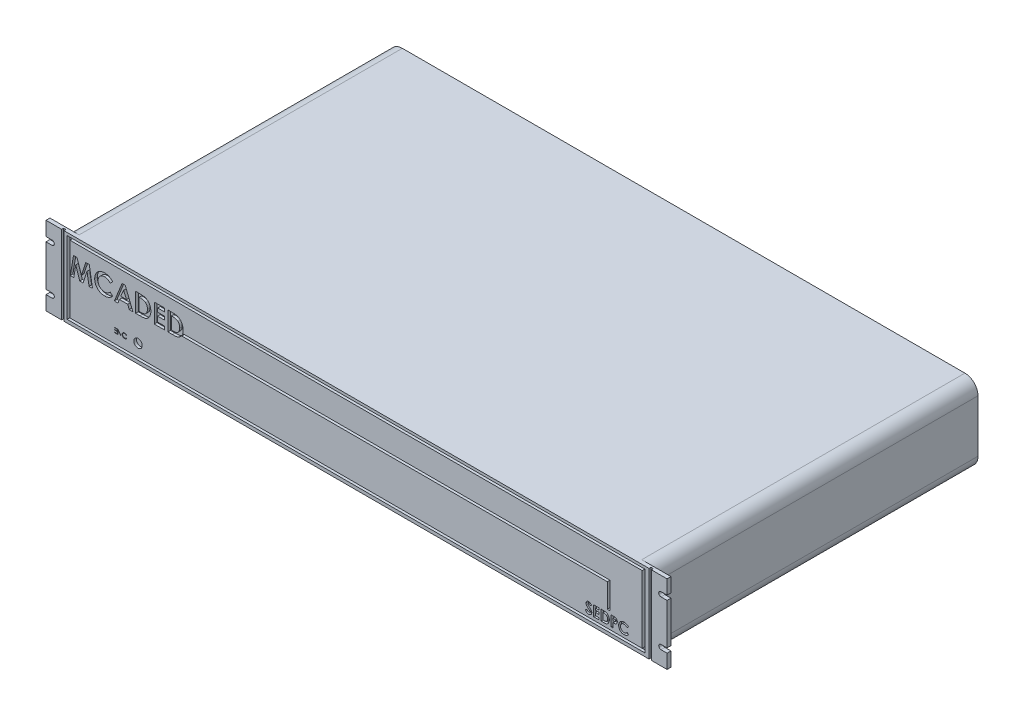
from build123d import *

# Parameters (mm, degrees)
CROQUIS1_W              = 450
CROQUIS1_H              = 60
SALIENTE_EXTRUIR1_DEPTH = 250
SALIENTE_EXTRUIR2_DEPTH = 3
CROQUIS3_W              = 1.774092819
CROQUIS3_H              = 60
CORTAR_EXTRUIR1_DEPTH   = 1.5
CROQUIS4_W              = 441.514510662
CROQUIS4_H              = 55.460871824
CROQUIS4_W_2            = 437.514510662
CROQUIS4_H_2            = 51.460871824
CORTAR_EXTRUIR2_DEPTH   = 2
CORTAR_EXTRUIR3_DEPTH   = 2
CORTAR_EXTRUIR4_DEPTH   = 2
CORTAR_EXTRUIR5_DEPTH   = 2
CORTAR_EXTRUIR6_DEPTH   = 2
CROQUIS9_R              = 3.233196097
CORTAR_EXTRUIR7_DEPTH   = 2
REDONDEO1_R             = 10
ESCALA1_SCALE           = 1.4


with BuildPart() as part:
    # Croquis1 → Saliente-Extruir1 (new body)
    with BuildSketch(Plane.XY):
        Rectangle(CROQUIS1_W, CROQUIS1_H)
    extrude(amount=-SALIENTE_EXTRUIR1_DEPTH)

    # Croquis2 → Saliente-Extruir2 (add)
    with BuildSketch(Plane.XY):
        with BuildLine():
            Line((-237.33757683, 19.209077648), (-232.703125908, 19.209077648))
            ThreePointArc((-232.703125908, 19.209077648), (-230.965960943, 17.471912682), (-232.703125908, 15.734747717))
            Line((-232.703125908, 15.734747717), (-237.33757683, 15.734747717))
            Line((-237.33757683, 15.734747717), (-237.33757683, -15.734747717))
            Line((-237.33757683, -15.734747717), (-232.703125908, -15.734747717))
            ThreePointArc((-232.703125908, -15.734747717), (-230.965960943, -17.471912682), (-232.703125908, -19.209077648))
            Line((-232.703125908, -19.209077648), (-237.33757683, -19.209077648))
            Line((-237.33757683, -19.209077648), (-237.33757683, -30))
            Line((-237.33757683, -30), (-225, -30))
            Line((-225, -30), (-225, 30))
            Line((-225, 30), (-237.33757683, 30))
            Line((-237.33757683, 30), (-237.33757683, 19.209077648))
        make_face()
        with BuildLine():
            Line((237.33757683, -19.209077648), (237.33757683, -30))
            Line((237.33757683, -30), (225, -30))
            Line((225, -30), (225, 30))
            Line((225, 30), (237.33757683, 30))
            Line((237.33757683, 30), (237.33757683, 19.209077648))
            Line((237.33757683, 19.209077648), (232.703125908, 19.209077648))
            ThreePointArc((232.703125908, 19.209077648), (230.965960943, 17.471912682), (232.703125908, 15.734747717))
            Line((232.703125908, 15.734747717), (237.33757683, 15.734747717))
            Line((237.33757683, 15.734747717), (237.33757683, -15.734747717))
            Line((237.33757683, -15.734747717), (232.703125908, -15.734747717))
            ThreePointArc((232.703125908, -15.734747717), (230.965960943, -17.471912682), (232.703125908, -19.209077648))
            Line((232.703125908, -19.209077648), (237.33757683, -19.209077648))
        make_face()
    extrude(amount=-SALIENTE_EXTRUIR2_DEPTH)

    # Croquis3 → Cortar-Extruir1 (cut)
    with BuildSketch(Plane.XY):
        with Locations((-224.462831351, 0)):
            Rectangle(CROQUIS3_W, CROQUIS3_H)
        with Locations((224.462831351, 0)):
            Rectangle(CROQUIS3_W, CROQUIS3_H)
    extrude(amount=-CORTAR_EXTRUIR1_DEPTH, mode=Mode.SUBTRACT)

    # Croquis4 → Cortar-Extruir2 (cut)
    with BuildSketch(Plane.XY):
        with Locations((-0.390933447, 0.235625417)):
            Rectangle(CROQUIS4_W, CROQUIS4_H)
        with Locations((-0.390933447, 0.235625417)):
            Rectangle(CROQUIS4_W_2, CROQUIS4_H_2, mode=Mode.SUBTRACT)
    extrude(amount=-CORTAR_EXTRUIR2_DEPTH, mode=Mode.SUBTRACT)

    # Croquis5 → Cortar-Extruir3 (cut)
    with BuildSketch(Plane.XY):
        Polygon((-133.60240972, 7.292609146), (193.704759811, 7.292609146), (193.704759811, -12.940905954), (191.704759811, -12.940905954), (191.704759811, 5.292609146), (-133.60240972, 5.292609146), align=None)
    extrude(amount=-CORTAR_EXTRUIR3_DEPTH, mode=Mode.SUBTRACT)

    # Croquis6 → Cortar-Extruir4 (cut)
    with BuildSketch(Plane.XY):
        Polygon((-216.317645325, 17.239226917), (-213.606620185, 17.239226917), (-210.286343158, 7.088915585), (-206.942745485, 17.239226917), (-204.257956072, 17.239226917), (-201.79762788, 2.687143583), (-204.441606162, 2.687143583), (-205.995344226, 11.878393333), (-209.021198093, 2.687143583), (-211.568978708, 2.687143583), (-214.57734209, 11.878393333), (-216.128165073, 2.687143583), (-218.775058436, 2.687143583), align=None)
        with BuildLine():
            Line((-186.312718692, 14.714766948), (-188.227926775, 12.884096208))
            add(Edge.make_bspline(
                [(-188.227926775, 12.884096208), (-188.390390328, 13.052083793), (-188.707732544, 13.380216176), (-189.219090278, 13.814634535), (-189.750883703, 14.176663457), (-190.292767839, 14.481561911), (-190.854489611, 14.712239321), (-191.429553985, 14.880337835), (-192.021632917, 14.982821146), (-192.422329165, 14.994547051), (-192.623868615, 15.000444866)],
                knots=[0, 0, 0, 0, 0.000700833, 0.001368946, 0.002008519, 0.002628308, 0.003230835, 0.003825862, 0.004422991, 0.005027264, 0.005027264, 0.005027264, 0.005027264], degree=3))
            add(Edge.make_bspline(
                [(-192.623868615, 15.000444866), (-192.792178549, 14.995785386), (-193.124319658, 14.986590415), (-193.611989843, 14.919182212), (-194.078471579, 14.80455163), (-194.525361706, 14.646569454), (-194.951345231, 14.442148903), (-195.357315281, 14.191448193), (-195.742270954, 13.896731509), (-196.101127208, 13.559523727), (-196.429396297, 13.191098886), (-196.71944294, 12.797990459), (-196.96240353, 12.381099037), (-197.161797334, 11.944646588), (-197.317117399, 11.486612995), (-197.42803544, 11.007306624), (-197.49218747, 10.506156658), (-197.501762591, 10.165478646), (-197.506628949, 9.992336058)],
                knots=[0, 0, 0, 0, 0.000504848, 0.000996262, 0.001473499, 0.001943722, 0.002415713, 0.002888181, 0.00337269, 0.003867671, 0.004363217, 0.00485123, 0.005330696, 0.005808138, 0.006288419, 0.006779158, 0.007281746, 0.007801154, 0.007801154, 0.007801154, 0.007801154], degree=3))
            add(Edge.make_bspline(
                [(-197.506628949, 9.992336058), (-197.50522652, 9.870812476), (-197.502462304, 9.631286998), (-197.47220307, 9.276962338), (-197.42347857, 8.933183651), (-197.352962145, 8.600471671), (-197.264780663, 8.278538067), (-197.161323706, 7.964605533), (-197.031538475, 7.66301191), (-196.88747491, 7.370254385), (-196.719930645, 7.094321213), (-196.539287019, 6.831196032), (-196.343408499, 6.582168657), (-196.13102637, 6.348257119), (-195.899151616, 6.133116932), (-195.653777343, 5.930278573), (-195.390764426, 5.744819775), (-195.115576309, 5.572086245), (-194.825835715, 5.422031157), (-194.529403978, 5.286110237), (-194.221786596, 5.175722242), (-193.906728994, 5.086739447), (-193.585357079, 5.01107287), (-193.254527533, 4.964482632), (-192.917108236, 4.929200391), (-192.689069426, 4.927021919), (-192.574312242, 4.925925635)],
                knots=[0, 0, 0, 0, 0.00036449, 0.000718417, 0.001065948, 0.001405552, 0.001737922, 0.002067017, 0.002396202, 0.002722118, 0.003045074, 0.003363659, 0.003679162, 0.003994866, 0.00431041, 0.004627296, 0.004949225, 0.005275219, 0.0056012, 0.005927377, 0.006252888, 0.00658043, 0.006909266, 0.007242377, 0.007582043, 0.007926134, 0.007926134, 0.007926134, 0.007926134], degree=3))
            add(Edge.make_bspline(
                [(-192.574312242, 4.925925635), (-192.379664336, 4.931555885), (-191.997231818, 4.942617863), (-191.435957109, 5.029120964), (-190.901118227, 5.171413669), (-190.47378452, 5.339453086), (-190.138979848, 5.505394192), (-189.884098001, 5.658881544), (-189.620530306, 5.830573998), (-189.352654396, 6.026951415), (-189.0774572, 6.245657186), (-188.799796581, 6.491481376), (-188.51256438, 6.756329347), (-188.324401413, 6.945356547), (-188.227926775, 7.042274293)],
                knots=[0, 0, 0, 0, 0.000583744, 0.001146906, 0.001699158, 0.002241026, 0.002521314, 0.00281928, 0.003132987, 0.003464756, 0.003815306, 0.004187158, 0.004577006, 0.004987205, 0.004987205, 0.004987205, 0.004987205], degree=3))
            Line((-188.227926775, 7.042274293), (-186.371020308, 5.09208524))
            add(Edge.make_bspline(
                [(-186.371020308, 5.09208524), (-186.501550838, 4.966062112), (-186.756318517, 4.720091916), (-187.140628488, 4.37083719), (-187.52445479, 4.056992994), (-187.898524979, 3.767168159), (-188.268966715, 3.509805985), (-188.635740712, 3.284649443), (-188.99469493, 3.086003998), (-189.353283167, 2.917219708), (-189.713736744, 2.773904315), (-190.084601116, 2.650519169), (-190.467010049, 2.546139774), (-190.863299124, 2.461919311), (-191.269771998, 2.394385869), (-191.690232715, 2.348801187), (-192.122015348, 2.318156121), (-192.414900198, 2.315402408), (-192.562651919, 2.314013242)],
                knots=[0, 0, 0, 0, 0.000544317, 0.00106239, 0.00155731, 0.002031331, 0.002481737, 0.002909708, 0.003321963, 0.003711865, 0.004097825, 0.004484993, 0.004883837, 0.005286351, 0.005699933, 0.006119391, 0.006554715, 0.006997893, 0.006997893, 0.006997893, 0.006997893], degree=3))
            add(Edge.make_bspline(
                [(-192.562651919, 2.314013242), (-192.834053528, 2.32093181), (-193.365111037, 2.334469525), (-194.143361969, 2.434774827), (-194.882679464, 2.602934899), (-195.584862143, 2.840759623), (-196.249686727, 3.144569562), (-196.876983135, 3.517026282), (-197.465740304, 3.957140223), (-198.011202235, 4.459752823), (-198.504598511, 5.014846247), (-198.940703681, 5.610864298), (-199.301449894, 6.250736189), (-199.600985248, 6.925008968), (-199.835217955, 7.636759602), (-200.000078072, 8.38675799), (-200.101746103, 9.174279961), (-200.11286873, 9.71217562), (-200.118541342, 9.986505897)],
                knots=[0, 0, 0, 0, 0.000814059, 0.001592888, 0.002349535, 0.003085165, 0.003813031, 0.004538441, 0.005269545, 0.006014307, 0.006759685, 0.007494377, 0.008225476, 0.008958919, 0.009704684, 0.010469219, 0.011259615, 0.012082293, 0.012082293, 0.012082293, 0.012082293], degree=3))
            add(Edge.make_bspline(
                [(-200.118541342, 9.986505897), (-200.116144371, 10.165421762), (-200.111394161, 10.519989279), (-200.061469009, 11.042295957), (-199.991870444, 11.551451543), (-199.88145865, 12.042169312), (-199.748368122, 12.52106014), (-199.582852564, 12.982919041), (-199.385176327, 13.429073445), (-199.161710983, 13.860270242), (-198.908906875, 14.273684629), (-198.626496933, 14.665764727), (-198.321751492, 15.039537321), (-197.987348013, 15.390043623), (-197.628145819, 15.720361148), (-197.242523151, 16.028699841), (-196.832799339, 16.319481628), (-196.397865411, 16.58520795), (-195.946170976, 16.825571533), (-195.483413089, 17.037582479), (-195.010728691, 17.214774808), (-194.530116337, 17.361749308), (-194.039545444, 17.471455379), (-193.542517582, 17.554499337), (-193.034803642, 17.60092144), (-192.693917716, 17.608521034), (-192.521840788, 17.612357259)],
                knots=[0, 0, 0, 0, 0.000536573, 0.001063356, 0.001572904, 0.002077221, 0.002570938, 0.003063319, 0.003547547, 0.004033877, 0.004519332, 0.004999852, 0.005482463, 0.005964959, 0.006451856, 0.006945358, 0.007445199, 0.007958154, 0.008473266, 0.008979417, 0.009484029, 0.009986616, 0.010485879, 0.010990996, 0.011497457, 0.012013723, 0.012013723, 0.012013723, 0.012013723], degree=3))
            add(Edge.make_bspline(
                [(-192.521840788, 17.612357259), (-192.375041524, 17.610158239), (-192.0829693, 17.605783064), (-191.648024746, 17.569311217), (-191.216558675, 17.51203255), (-190.790115869, 17.42561124), (-190.365645971, 17.323018224), (-189.948726992, 17.188686822), (-189.53278181, 17.038949158), (-189.124333907, 16.859968356), (-188.72281315, 16.664594644), (-188.337625795, 16.442936072), (-187.962304581, 16.208633261), (-187.605166403, 15.947819146), (-187.259521292, 15.669953937), (-186.927176656, 15.373741239), (-186.611049016, 15.054242316), (-186.412664861, 14.828497467), (-186.312718692, 14.714766948)],
                knots=[0, 0, 0, 0, 0.000440332, 0.000876085, 0.00130855, 0.001745326, 0.002180845, 0.002617855, 0.003058678, 0.00350652, 0.003954988, 0.004397553, 0.004839118, 0.005281692, 0.005723295, 0.006169217, 0.006616518, 0.007070672, 0.007070672, 0.007070672, 0.007070672], degree=3))
        make_face()
        Polygon((-179.220327116, 17.239226917), (-176.797894974, 17.239226917), (-170.92109209, 2.687143583), (-173.710824411, 2.687143583), (-174.84187576, 5.672186319), (-181.182176491, 5.672186319), (-182.31322784, 2.687143583), (-185.100045081, 2.687143583), align=None)
        Polygon((-178.010568585, 13.335933731), (-180.191049021, 8.284098712), (-175.83008815, 8.284098712), align=None, mode=Mode.SUBTRACT)
        with BuildLine():
            Line((-168.775592624, 17.239226917), (-165.484466405, 17.239226917))
            add(Edge.make_bspline(
                [(-165.484466405, 17.239226917), (-165.227885262, 17.237433327), (-164.731911011, 17.233966297), (-164.013342441, 17.194901209), (-163.345165111, 17.134821878), (-162.7269483, 17.05217187), (-162.159959453, 16.942803275), (-161.644929689, 16.805621809), (-161.180130446, 16.647268629), (-160.760465297, 16.460933979), (-160.37735138, 16.243686283), (-160.013572489, 16.001689791), (-159.669842894, 15.726079464), (-159.341338896, 15.422172375), (-159.032299907, 15.084408637), (-158.737579321, 14.718382842), (-158.464393236, 14.318787109), (-158.204483827, 13.895202486), (-157.969430351, 13.44583386), (-157.764407927, 12.974506163), (-157.592659399, 12.484252565), (-157.453104825, 11.974550584), (-157.341863725, 11.447092274), (-157.264030568, 10.900813275), (-157.215913336, 10.336219349), (-157.211032245, 9.953566324), (-157.208552026, 9.759129594)],
                knots=[0, 0, 0, 0, 0.00076967, 0.00148778, 0.002158135, 0.002781887, 0.003358159, 0.003889192, 0.004379637, 0.004829826, 0.005264447, 0.005699419, 0.006139201, 0.006584741, 0.00704066, 0.007511398, 0.007993331, 0.008491775, 0.00900159, 0.009513359, 0.010032415, 0.010558585, 0.011097717, 0.01164849, 0.012213031, 0.012796229, 0.012796229, 0.012796229, 0.012796229], degree=3))
            add(Edge.make_bspline(
                [(-157.208552026, 9.759129594), (-157.215046578, 9.484766713), (-157.227831485, 8.944667321), (-157.335524401, 8.152077685), (-157.50970031, 7.392301467), (-157.754607457, 6.671281932), (-158.05822676, 5.995439864), (-158.420934017, 5.376693456), (-158.837411094, 4.818363824), (-159.302806008, 4.323230992), (-159.806715354, 3.897657613), (-160.330378778, 3.533185157), (-160.878897717, 3.245768213), (-161.36221956, 3.06350289), (-161.781319895, 2.950149628), (-162.149285456, 2.883156758), (-162.567256788, 2.821720257), (-163.039131111, 2.77424345), (-163.562838414, 2.731905805), (-164.140466203, 2.708901177), (-164.770144282, 2.689787746), (-165.207515245, 2.688048066), (-165.434910032, 2.687143583)],
                knots=[0, 0, 0, 0, 0.000822797, 0.001619724, 0.002394724, 0.003158008, 0.003900347, 0.004613779, 0.005305238, 0.00598577, 0.006647551, 0.007280668, 0.007896109, 0.008500347, 0.008826328, 0.009197368, 0.00962158, 0.010093517, 0.010619817, 0.011197599, 0.011827499, 0.012509653, 0.012509653, 0.012509653, 0.012509653], degree=3))
            Line((-165.434910032, 2.687143583), (-168.775592624, 2.687143583))
            Line((-168.775592624, 2.687143583), (-168.775592624, 17.239226917))
        make_face()
        with BuildLine():
            Line((-166.163680231, 14.627314524), (-166.163680231, 5.299055977))
            Line((-166.163680231, 5.299055977), (-164.799422418, 5.299055977))
            add(Edge.make_bspline(
                [(-164.799422418, 5.299055977), (-164.63709669, 5.299353425), (-164.324890277, 5.299925516), (-163.874134887, 5.327174723), (-163.457300445, 5.354525413), (-163.075534396, 5.406437938), (-162.726058367, 5.464264837), (-162.413673244, 5.544738885), (-162.131939411, 5.629270055), (-161.884298193, 5.736888712), (-161.657479015, 5.858020673), (-161.447470364, 5.999940808), (-161.244753218, 6.157537765), (-161.053117537, 6.335446696), (-160.871838027, 6.531311751), (-160.701987252, 6.746142137), (-160.541298153, 6.9792824), (-160.393895316, 7.231965209), (-160.259197814, 7.501522179), (-160.139706036, 7.785342255), (-160.04062972, 8.085789049), (-159.958283552, 8.400050016), (-159.899437877, 8.730861156), (-159.850754305, 9.075772196), (-159.825656506, 9.436149644), (-159.822211989, 9.681362504), (-159.820464419, 9.805770887)],
                knots=[0, 0, 0, 0, 0.000486853, 0.000936381, 0.001354469, 0.001739547, 0.002091802, 0.00241632, 0.002706732, 0.00297314, 0.003224868, 0.00347712, 0.003732535, 0.003994519, 0.004260623, 0.004532414, 0.004815417, 0.005109393, 0.005409236, 0.005718907, 0.006032329, 0.006357566, 0.006692611, 0.007039738, 0.007402159, 0.007775392, 0.007775392, 0.007775392, 0.007775392], degree=3))
            add(Edge.make_bspline(
                [(-159.820464419, 9.805770887), (-159.823944986, 9.996414973), (-159.830731822, 10.36815617), (-159.896182598, 10.909605336), (-160.002723977, 11.41946084), (-160.15474826, 11.895830469), (-160.34637958, 12.340053073), (-160.586250848, 12.748365145), (-160.864038928, 13.127625766), (-161.083706163, 13.350112215), (-161.193467474, 13.461282205)],
                knots=[0, 0, 0, 0, 0.00057172, 0.00111481, 0.001633375, 0.002132126, 0.002612514, 0.003081488, 0.003550237, 0.004018368, 0.004018368, 0.004018368, 0.004018368], degree=3))
            add(Edge.make_bspline(
                [(-161.193467474, 13.461282205), (-161.301702519, 13.556014066), (-161.522760343, 13.749493164), (-161.91086524, 13.981330603), (-162.338536736, 14.185022516), (-162.815558672, 14.346527488), (-163.337320843, 14.474252505), (-163.906930877, 14.562341326), (-164.521338387, 14.618946268), (-164.946985593, 14.624465344), (-165.166722599, 14.627314524)],
                knots=[0, 0, 0, 0, 0.000430722, 0.000879702, 0.00135044, 0.001850102, 0.002387434, 0.002960135, 0.003577705, 0.004236746, 0.004236746, 0.004236746, 0.004236746], degree=3))
            Line((-165.166722599, 14.627314524), (-166.163680231, 14.627314524))
        make_face(mode=Mode.SUBTRACT)
        Polygon((-154.596639632, 17.239226917), (-146.760902453, 17.239226917), (-146.760902453, 14.627314524), (-151.984727239, 14.627314524), (-151.984727239, 11.82883696), (-146.760902453, 11.82883696), (-146.760902453, 9.216924566), (-151.984727239, 9.216924566), (-151.984727239, 5.299055977), (-146.760902453, 5.299055977), (-146.760902453, 2.687143583), (-154.596639632, 2.687143583), align=None)
        with BuildLine():
            Line((-144.14899006, 17.239226917), (-140.857863841, 17.239226917))
            add(Edge.make_bspline(
                [(-140.857863841, 17.239226917), (-140.601282698, 17.237433327), (-140.105308447, 17.233966297), (-139.386739877, 17.194901209), (-138.718562547, 17.134821878), (-138.100345736, 17.05217187), (-137.533356888, 16.942803275), (-137.018327125, 16.805621809), (-136.553527882, 16.647268629), (-136.133862733, 16.460933979), (-135.750748816, 16.243686283), (-135.386969925, 16.001689791), (-135.04324033, 15.726079464), (-134.714736332, 15.422172375), (-134.405697343, 15.084408637), (-134.110976757, 14.718382842), (-133.837790672, 14.318787109), (-133.577881263, 13.895202486), (-133.342827787, 13.44583386), (-133.137805363, 12.974506163), (-132.966056835, 12.484252565), (-132.826502261, 11.974550584), (-132.715261161, 11.447092274), (-132.637428004, 10.900813275), (-132.589310772, 10.336219349), (-132.584429681, 9.953566324), (-132.581949462, 9.759129594)],
                knots=[0, 0, 0, 0, 0.00076967, 0.00148778, 0.002158135, 0.002781887, 0.003358159, 0.003889192, 0.004379637, 0.004829826, 0.005264447, 0.005699419, 0.006139201, 0.006584741, 0.00704066, 0.007511398, 0.007993331, 0.008491775, 0.00900159, 0.009513359, 0.010032415, 0.010558585, 0.011097717, 0.01164849, 0.012213031, 0.012796229, 0.012796229, 0.012796229, 0.012796229], degree=3))
            add(Edge.make_bspline(
                [(-132.581949462, 9.759129594), (-132.588444014, 9.484766713), (-132.601228921, 8.944667321), (-132.708921837, 8.152077685), (-132.883097746, 7.392301467), (-133.128004893, 6.671281932), (-133.431624196, 5.995439864), (-133.794331453, 5.376693456), (-134.21080853, 4.818363824), (-134.676203444, 4.323230992), (-135.18011279, 3.897657613), (-135.703776214, 3.533185157), (-136.252295153, 3.245768213), (-136.735616996, 3.06350289), (-137.154717331, 2.950149628), (-137.522682891, 2.883156758), (-137.940654224, 2.821720257), (-138.412528546, 2.77424345), (-138.93623585, 2.731905805), (-139.513863638, 2.708901177), (-140.143541718, 2.689787746), (-140.580912681, 2.688048066), (-140.808307468, 2.687143583)],
                knots=[0, 0, 0, 0, 0.000822797, 0.001619724, 0.002394724, 0.003158008, 0.003900347, 0.004613779, 0.005305238, 0.00598577, 0.006647551, 0.007280668, 0.007896109, 0.008500347, 0.008826328, 0.009197368, 0.00962158, 0.010093517, 0.010619817, 0.011197599, 0.011827499, 0.012509653, 0.012509653, 0.012509653, 0.012509653], degree=3))
            Line((-140.808307468, 2.687143583), (-144.14899006, 2.687143583))
            Line((-144.14899006, 2.687143583), (-144.14899006, 17.239226917))
        make_face()
        with BuildLine():
            Line((-141.537077667, 14.627314524), (-141.537077667, 5.299055977))
            Line((-141.537077667, 5.299055977), (-140.172819854, 5.299055977))
            add(Edge.make_bspline(
                [(-140.172819854, 5.299055977), (-140.010494126, 5.299353425), (-139.698287713, 5.299925516), (-139.247532323, 5.327174723), (-138.830697881, 5.354525413), (-138.448931832, 5.406437938), (-138.099455803, 5.464264837), (-137.78707068, 5.544738885), (-137.505336847, 5.629270055), (-137.257695629, 5.736888712), (-137.03087645, 5.858020673), (-136.820867799, 5.999940808), (-136.618150653, 6.157537765), (-136.426514973, 6.335446696), (-136.245235463, 6.531311751), (-136.075384688, 6.746142137), (-135.914695589, 6.9792824), (-135.767292752, 7.231965209), (-135.63259525, 7.501522179), (-135.513103472, 7.785342255), (-135.414027156, 8.085789049), (-135.331680988, 8.400050016), (-135.272835313, 8.730861156), (-135.224151741, 9.075772196), (-135.199053942, 9.436149644), (-135.195609425, 9.681362504), (-135.193861855, 9.805770887)],
                knots=[0, 0, 0, 0, 0.000486853, 0.000936381, 0.001354469, 0.001739547, 0.002091802, 0.00241632, 0.002706732, 0.00297314, 0.003224868, 0.00347712, 0.003732535, 0.003994519, 0.004260623, 0.004532414, 0.004815417, 0.005109393, 0.005409236, 0.005718907, 0.006032329, 0.006357566, 0.006692611, 0.007039738, 0.007402159, 0.007775392, 0.007775392, 0.007775392, 0.007775392], degree=3))
            add(Edge.make_bspline(
                [(-135.193861855, 9.805770887), (-135.197342422, 9.996414973), (-135.204129258, 10.36815617), (-135.269580034, 10.909605336), (-135.376121413, 11.41946084), (-135.528145696, 11.895830469), (-135.719777016, 12.340053073), (-135.959648284, 12.748365145), (-136.237436364, 13.127625766), (-136.457103599, 13.350112215), (-136.56686491, 13.461282205)],
                knots=[0, 0, 0, 0, 0.00057172, 0.00111481, 0.001633375, 0.002132126, 0.002612514, 0.003081488, 0.003550237, 0.004018368, 0.004018368, 0.004018368, 0.004018368], degree=3))
            add(Edge.make_bspline(
                [(-136.56686491, 13.461282205), (-136.675099955, 13.556014066), (-136.896157779, 13.749493164), (-137.284262676, 13.981330603), (-137.711934171, 14.185022516), (-138.188956108, 14.346527488), (-138.710718279, 14.474252505), (-139.280328313, 14.562341326), (-139.894735822, 14.618946268), (-140.320383029, 14.624465344), (-140.540120034, 14.627314524)],
                knots=[0, 0, 0, 0, 0.000430722, 0.000879702, 0.00135044, 0.001850102, 0.002387434, 0.002960135, 0.003577705, 0.004236746, 0.004236746, 0.004236746, 0.004236746], degree=3))
            Line((-140.540120034, 14.627314524), (-141.537077667, 14.627314524))
        make_face(mode=Mode.SUBTRACT)
    extrude(amount=-CORTAR_EXTRUIR4_DEPTH, mode=Mode.SUBTRACT)

    # Croquis7 → Cortar-Extruir5 (cut)
    with BuildSketch(Plane.XY):
        with BuildLine():
            Line((179.591528096, -16.287805815), (178.526198569, -17.26250283))
            add(Edge.make_bspline(
                [(178.526198569, -17.26250283), (178.48056442, -17.198131119), (178.392953218, -17.07454641), (178.250944597, -16.909063573), (178.109577219, -16.767894397), (177.967541399, -16.651628623), (177.823578187, -16.560972652), (177.677937481, -16.496787223), (177.53144496, -16.455983936), (177.433024599, -16.450902945), (177.384546926, -16.448400266)],
                knots=[0, 0, 0, 0, 0.000236612, 0.000454262, 0.000653272, 0.000835296, 0.001003841, 0.001161896, 0.001311538, 0.00145679, 0.00145679, 0.00145679, 0.00145679], degree=3))
            add(Edge.make_bspline(
                [(177.384546926, -16.448400266), (177.339328343, -16.449986078), (177.252023141, -16.453047866), (177.127563097, -16.483481803), (177.017065698, -16.53600631), (176.920638784, -16.604686521), (176.844254441, -16.687430252), (176.783267467, -16.774207152), (176.748926676, -16.869989223), (176.744406752, -16.935776214), (176.742169122, -16.968344677)],
                knots=[0, 0, 0, 0, 0.00013549, 0.000261596, 0.000381093, 0.000500685, 0.000614292, 0.000717486, 0.000817064, 0.000914693, 0.000914693, 0.000914693, 0.000914693], degree=3))
            add(Edge.make_bspline(
                [(176.742169122, -16.968344677), (176.743571331, -17.001382792), (176.746395186, -17.067916963), (176.773669783, -17.165431078), (176.814780388, -17.260713719), (176.85406325, -17.318716797), (176.874142779, -17.34836521)],
                knots=[0, 0, 0, 0, 9.8903e-05, 0.000199176, 0.000301694, 0.00040889, 0.00040889, 0.00040889, 0.00040889], degree=3))
            add(Edge.make_bspline(
                [(176.874142779, -17.34836521), (176.892397244, -17.371410611), (176.93441661, -17.424458081), (177.014538935, -17.508477004), (177.115155748, -17.611407539), (177.240138996, -17.729710207), (177.384300281, -17.867639634), (177.554321664, -18.019773761), (177.745309188, -18.190824007), (177.881058696, -18.309937204), (177.952192659, -18.372353591)],
                knots=[0, 0, 0, 0, 8.8158e-05, 0.000202928, 0.000347971, 0.000520027, 0.000719112, 0.000946505, 0.001204392, 0.001488294, 0.001488294, 0.001488294, 0.001488294], degree=3))
            add(Edge.make_bspline(
                [(177.952192659, -18.372353591), (178.018962116, -18.430139189), (178.145676675, -18.539804247), (178.325966328, -18.69545619), (178.484410906, -18.835492448), (178.623318585, -18.957811376), (178.74058366, -19.063696379), (178.836699114, -19.153653588), (178.912838834, -19.2259317), (178.956119807, -19.269587724), (178.974590997, -19.288218976)],
                knots=[0, 0, 0, 0, 0.000264908, 0.000502741, 0.000714545, 0.000899278, 0.001058004, 0.001188504, 0.001294215, 0.001372918, 0.001372918, 0.001372918, 0.001372918], degree=3))
            add(Edge.make_bspline(
                [(178.974590997, -19.288218976), (179.04466684, -19.364056047), (179.17937722, -19.509841529), (179.354453226, -19.735763178), (179.498546443, -19.956308774), (179.610019687, -20.17562824), (179.694208765, -20.396885919), (179.75356318, -20.625508144), (179.789110934, -20.863883874), (179.793057565, -21.026546209), (179.795053737, -21.108819437)],
                knots=[0, 0, 0, 0, 0.000309651, 0.000595257, 0.000856359, 0.001098844, 0.001331844, 0.001565169, 0.001806227, 0.002052936, 0.002052936, 0.002052936, 0.002052936], degree=3))
            add(Edge.make_bspline(
                [(179.795053737, -21.108819437), (179.793632913, -21.188984607), (179.790845202, -21.346271654), (179.756701099, -21.576437819), (179.708013612, -21.796716828), (179.632734215, -22.004711734), (179.540984131, -22.203836711), (179.425962151, -22.390990023), (179.290884607, -22.56806574), (179.136065001, -22.731898416), (178.964816133, -22.880565215), (178.781135446, -23.01291191), (178.58322682, -23.122180964), (178.372781153, -23.212156237), (178.149911093, -23.281456395), (177.914882144, -23.33267567), (177.667334815, -23.363416672), (177.498058384, -23.366630279), (177.411577675, -23.368272061)],
                knots=[0, 0, 0, 0, 0.000240286, 0.00047145, 0.000696698, 0.000915963, 0.001133631, 0.001353425, 0.001573496, 0.001800711, 0.00202837, 0.00225295, 0.002478585, 0.002705114, 0.002938456, 0.003177666, 0.003425968, 0.00368532, 0.00368532, 0.00368532, 0.00368532], degree=3))
            add(Edge.make_bspline(
                [(177.411577675, -23.368272061), (177.343691055, -23.367067707), (177.209236614, -23.364682396), (177.011071094, -23.345208314), (176.819719884, -23.313779218), (176.635398523, -23.268731934), (176.457276611, -23.211650917), (176.285346832, -23.14192864), (176.120796075, -23.058484436), (175.962379271, -22.963034248), (175.810866522, -22.852204007), (175.664342007, -22.728259601), (175.524261147, -22.589294709), (175.389951163, -22.435637978), (175.262271408, -22.266854289), (175.137042464, -22.085294267), (175.019829883, -21.887588404), (174.947422458, -21.748896142), (174.910438352, -21.678055214)],
                knots=[0, 0, 0, 0, 0.000203625, 0.000403294, 0.000596731, 0.000784928, 0.000971987, 0.001157416, 0.001340879, 0.001524946, 0.00171164, 0.001903423, 0.002100184, 0.002303013, 0.002515133, 0.002734767, 0.002964373, 0.003204095, 0.003204095, 0.003204095, 0.003204095], degree=3))
            Line((174.910438352, -21.678055214), (176.16339308, -20.925964369))
            add(Edge.make_bspline(
                [(176.16339308, -20.925964369), (176.209654668, -21.006378078), (176.298342087, -21.160538033), (176.448631209, -21.36767147), (176.602594742, -21.545046972), (176.763792186, -21.689529416), (176.930263438, -21.803050717), (177.102812595, -21.884180915), (177.281560885, -21.934400415), (177.4033161, -21.940533376), (177.46404913, -21.943592574)],
                knots=[0, 0, 0, 0, 0.000278144, 0.000533226, 0.000766421, 0.000981524, 0.001180858, 0.001368651, 0.001551479, 0.00173344, 0.00173344, 0.00173344, 0.00173344], degree=3))
            add(Edge.make_bspline(
                [(177.46404913, -21.943592574), (177.525823315, -21.941094267), (177.645674232, -21.936247188), (177.816746079, -21.891476179), (177.973591226, -21.821182411), (178.109167012, -21.720882897), (178.22396404, -21.605122014), (178.308690836, -21.476332738), (178.361916781, -21.336985851), (178.367544054, -21.240186337), (178.37037425, -21.191501728)],
                knots=[0, 0, 0, 0, 0.000184999, 0.000358926, 0.000526839, 0.000697634, 0.000861802, 0.001013516, 0.001157377, 0.001302942, 0.001302942, 0.001302942, 0.001302942], degree=3))
            add(Edge.make_bspline(
                [(178.37037425, -21.191501728), (178.36776068, -21.146208622), (178.362451463, -21.054200013), (178.323345405, -20.917398007), (178.26221071, -20.780658216), (178.189884054, -20.668500539), (178.116282625, -20.574593957), (178.045903058, -20.493228152), (177.960199363, -20.403333181), (177.859388847, -20.304795964), (177.74480348, -20.196749053), (177.616346739, -20.079203029), (177.472547657, -19.95319333), (177.370910182, -19.867356769), (177.317765075, -19.822473784)],
                knots=[0, 0, 0, 0, 0.000135751, 0.000275765, 0.00042381, 0.000583932, 0.000674578, 0.000781679, 0.000906525, 0.001047071, 0.001204542, 0.001378991, 0.001569405, 0.001778089, 0.001778089, 0.001778089, 0.001778089], degree=3))
            add(Edge.make_bspline(
                [(177.317765075, -19.822473784), (177.216734111, -19.7369919), (177.022825112, -19.572926292), (176.748807094, -19.330606555), (176.501892325, -19.104136556), (176.284213426, -18.890716632), (176.09299683, -18.694288155), (175.929537539, -18.513255657), (175.795631229, -18.34622272), (175.654723712, -18.148383384), (175.520833398, -17.907302559), (175.405114171, -17.617254379), (175.330040421, -17.327243002), (175.321629452, -17.132545337), (175.317489634, -17.036716572)],
                knots=[0, 0, 0, 0, 0.000397015, 0.000761991, 0.001097313, 0.001402026, 0.001676399, 0.001919629, 0.002133436, 0.002318278, 0.002647851, 0.002957583, 0.003253762, 0.003540835, 0.003540835, 0.003540835, 0.003540835], degree=3))
            add(Edge.make_bspline(
                [(175.317489634, -17.036716572), (175.319211379, -16.968759955), (175.322603401, -16.83487812), (175.352860759, -16.638024389), (175.398081534, -16.448077079), (175.463755082, -16.265729204), (175.548991417, -16.091209162), (175.652507635, -15.923662605), (175.775911147, -15.764631592), (175.914978573, -15.61422155), (176.068195273, -15.476763889), (176.231926787, -15.35544373), (176.405246381, -15.252974959), (176.587093774, -15.167969673), (176.778595798, -15.102903527), (176.978341666, -15.056781399), (177.186617878, -15.029349429), (177.328282862, -15.025620371), (177.400447367, -15.023720779)],
                knots=[0, 0, 0, 0, 0.000203749, 0.000401408, 0.00059616, 0.000788792, 0.000981509, 0.001177865, 0.001378545, 0.001584448, 0.00179163, 0.001995162, 0.002194774, 0.002394671, 0.002596306, 0.00280034, 0.003008806, 0.003225262, 0.003225262, 0.003225262, 0.003225262], degree=3))
            add(Edge.make_bspline(
                [(177.400447367, -15.023720779), (177.493968993, -15.027141999), (177.68027402, -15.033957434), (177.955731374, -15.087251907), (178.224786602, -15.17106308), (178.441596346, -15.272172038), (178.614107813, -15.370116335), (178.746321738, -15.460291105), (178.880856523, -15.563591151), (179.018797107, -15.680341998), (179.157580342, -15.812743386), (179.301152498, -15.957643395), (179.44755723, -16.116294301), (179.542697092, -16.229633772), (179.591528096, -16.287805815)],
                knots=[0, 0, 0, 0, 0.000280394, 0.000558574, 0.000838679, 0.001123976, 0.001274258, 0.001433461, 0.001603603, 0.001782969, 0.001975311, 0.002178818, 0.002394877, 0.002622703, 0.002622703, 0.002622703, 0.002622703], degree=3))
        make_face()
        Polygon((181.219733224, -15.22724642), (185.493771686, -15.22724642), (185.493771686, -16.651925907), (182.644412711, -16.651925907), (182.644412711, -18.178368215), (185.493771686, -18.178368215), (185.493771686, -19.603047702), (182.644412711, -19.603047702), (182.644412711, -21.740066933), (185.493771686, -21.740066933), (185.493771686, -23.16474642), (181.219733224, -23.16474642), align=None)
        with BuildLine():
            Line((186.918451173, -15.22724642), (188.713610928, -15.22724642))
            add(Edge.make_bspline(
                [(188.713610928, -15.22724642), (188.853564279, -15.228224742), (189.124095689, -15.230115849), (189.516042181, -15.251424078), (189.880502543, -15.284194623), (190.217711713, -15.329276446), (190.526978357, -15.388932042), (190.807903683, -15.463758297), (191.061430542, -15.550132759), (191.290338806, -15.65176984), (191.499310033, -15.770268584), (191.697734883, -15.90226667), (191.885223752, -16.052599576), (192.064407752, -16.218367079), (192.232974473, -16.402601845), (192.393731156, -16.602252279), (192.542741748, -16.820213588), (192.684510517, -17.051259746), (192.812721503, -17.296369906), (192.924551917, -17.55345774), (193.018232932, -17.820868793), (193.094353608, -18.098888056), (193.155030572, -18.386592588), (193.197485021, -18.684562952), (193.223730785, -18.992523275), (193.226393198, -19.201243107), (193.227746045, -19.307299505)],
                knots=[0, 0, 0, 0, 0.00041982, 0.000811516, 0.001177164, 0.001517393, 0.001831723, 0.002121378, 0.002388893, 0.00263445, 0.002871516, 0.003108774, 0.003348655, 0.003591677, 0.00384036, 0.004097126, 0.004359999, 0.004631878, 0.004909958, 0.005189105, 0.005472226, 0.005759228, 0.0060533, 0.006353722, 0.006661653, 0.006979761, 0.006979761, 0.006979761, 0.006979761], degree=3))
            add(Edge.make_bspline(
                [(193.227746045, -19.307299505), (193.224203561, -19.456951986), (193.217229976, -19.751551654), (193.158488385, -20.183873274), (193.063483344, -20.598296665), (192.929897627, -20.991580048), (192.764287098, -21.360221176), (192.566446777, -21.697719217), (192.339277462, -22.002262652), (192.08542569, -22.272335106), (191.810566047, -22.50446604), (191.524931452, -22.703269198), (191.225739304, -22.860042077), (190.962109208, -22.959459526), (190.733509025, -23.021288578), (190.532800537, -23.057830143), (190.304816174, -23.091340962), (190.04743018, -23.117237402), (189.761771651, -23.140330662), (189.446701948, -23.152878642), (189.103241177, -23.163304149), (188.864675198, -23.164253066), (188.740641678, -23.16474642)],
                knots=[0, 0, 0, 0, 0.000448798, 0.000883486, 0.001306213, 0.00172255, 0.002127462, 0.002516607, 0.002893766, 0.003264966, 0.003625937, 0.003971273, 0.004306968, 0.004636553, 0.004814361, 0.005016746, 0.005248135, 0.005505555, 0.005792627, 0.006107781, 0.006451363, 0.006823447, 0.006823447, 0.006823447, 0.006823447], degree=3))
            Line((188.740641678, -23.16474642), (186.918451173, -23.16474642))
            Line((186.918451173, -23.16474642), (186.918451173, -15.22724642))
        make_face()
        with BuildLine():
            Line((188.34313066, -16.651925907), (188.34313066, -21.740066933))
            Line((188.34313066, -21.740066933), (189.087271285, -21.740066933))
            add(Edge.make_bspline(
                [(189.087271285, -21.740066933), (189.175812591, -21.739904688), (189.346106998, -21.739592638), (189.591973575, -21.724729434), (189.819337816, -21.709810876), (190.027573843, -21.681494954), (190.218197131, -21.649953009), (190.388589016, -21.606058074), (190.542262016, -21.559950163), (190.677339044, -21.501249077), (190.801058596, -21.435177098), (190.915608769, -21.357766116), (191.026181758, -21.271804139), (191.130710311, -21.174762904), (191.229590044, -21.067927419), (191.322235921, -20.950747209), (191.409884521, -20.823579793), (191.490286068, -20.685752806), (191.563757433, -20.538721732), (191.628934766, -20.383910781), (191.682976393, -20.220030711), (191.727892485, -20.048615638), (191.759990125, -19.868173199), (191.786544801, -19.680039904), (191.80023451, -19.483470387), (191.802113337, -19.349717918), (191.803066557, -19.2818588)],
                knots=[0, 0, 0, 0, 0.000265556, 0.000510753, 0.000738801, 0.000948844, 0.001140983, 0.001317992, 0.0014764, 0.001621712, 0.001759019, 0.001896611, 0.002035928, 0.002178829, 0.002323976, 0.002472226, 0.002626591, 0.002786942, 0.002950492, 0.003119404, 0.003290361, 0.003467764, 0.003650515, 0.003839857, 0.004037541, 0.004241123, 0.004241123, 0.004241123, 0.004241123], degree=3))
            add(Edge.make_bspline(
                [(191.803066557, -19.2818588), (191.801168066, -19.177871116), (191.797466156, -18.975103191), (191.761765732, -18.679767282), (191.703652253, -18.40166428), (191.620729917, -18.141826301), (191.516203742, -17.899523062), (191.385364869, -17.676807386), (191.233844098, -17.469937957), (191.114025606, -17.348581712), (191.0541558, -17.287943535)],
                knots=[0, 0, 0, 0, 0.000311847, 0.000608078, 0.000890932, 0.001162978, 0.001425007, 0.001680812, 0.001936493, 0.002191837, 0.002191837, 0.002191837, 0.002191837], degree=3))
            add(Edge.make_bspline(
                [(191.0541558, -17.287943535), (190.995118503, -17.236271611), (190.874541508, -17.130737558), (190.662847928, -17.004280773), (190.429572566, -16.893176093), (190.169378783, -16.805082472), (189.884781235, -16.735414281), (189.574084853, -16.687365833), (189.238953484, -16.65649041), (189.00678228, -16.653480005), (188.886925732, -16.651925907)],
                knots=[0, 0, 0, 0, 0.000234939, 0.000479837, 0.000736603, 0.001009146, 0.001302237, 0.001614619, 0.001951476, 0.002310952, 0.002310952, 0.002310952, 0.002310952], degree=3))
            Line((188.886925732, -16.651925907), (188.34313066, -16.651925907))
        make_face(mode=Mode.SUBTRACT)
        with BuildLine():
            Line((194.652425532, -15.22724642), (196.242469602, -15.22724642))
            add(Edge.make_bspline(
                [(196.242469602, -15.22724642), (196.346361019, -15.22771146), (196.546789339, -15.22860862), (196.835823467, -15.239487876), (197.102471601, -15.258984166), (197.346672481, -15.283078497), (197.568325696, -15.316857811), (197.767708823, -15.355583151), (197.944863239, -15.402761885), (198.101786623, -15.458762388), (198.242620291, -15.524784794), (198.375894365, -15.595103369), (198.498596834, -15.679026108), (198.616920864, -15.767508174), (198.724101666, -15.869002226), (198.826825819, -15.976753688), (198.920742676, -16.095035893), (199.006287413, -16.222417067), (199.08388967, -16.35654375), (199.151688194, -16.497655723), (199.206682559, -16.645976278), (199.252815994, -16.800545952), (199.289870817, -16.961358008), (199.314535688, -17.129401453), (199.331289309, -17.303502946), (199.332767584, -17.421996531), (199.333515275, -17.481928912)],
                knots=[0, 0, 0, 0, 0.000311665, 0.000601267, 0.000867489, 0.001113674, 0.001337198, 0.00153989, 0.001722717, 0.001886684, 0.002038939, 0.002189061, 0.002338119, 0.002484412, 0.002631806, 0.002780286, 0.00293077, 0.00308424, 0.003240243, 0.003395286, 0.003553286, 0.003714266, 0.003878971, 0.004047853, 0.004223479, 0.004403218, 0.004403218, 0.004403218, 0.004403218], degree=3))
            add(Edge.make_bspline(
                [(199.333515275, -17.481928912), (199.33243346, -17.548230678), (199.33030756, -17.678521795), (199.309466891, -17.869512588), (199.273864444, -18.051605017), (199.227333908, -18.2263347), (199.162450384, -18.390826947), (199.088324006, -18.549006593), (198.997125047, -18.696438766), (198.892915658, -18.834967665), (198.779107116, -18.965719596), (198.652997612, -19.084919343), (198.516990847, -19.193379488), (198.371874115, -19.292236701), (198.217102605, -19.381291565), (198.052787992, -19.461377985), (197.877808243, -19.529934548), (197.75595761, -19.565789075), (197.694179839, -19.583967173)],
                knots=[0, 0, 0, 0, 0.000198857, 0.000390779, 0.000575388, 0.000755148, 0.000932322, 0.00110514, 0.001278579, 0.001451258, 0.001624769, 0.001797975, 0.001971056, 0.002146141, 0.002324234, 0.002506285, 0.002694078, 0.002887202, 0.002887202, 0.002887202, 0.002887202], degree=3))
            add(Edge.make_bspline(
                [(197.694179839, -19.583967173), (197.653489445, -19.594091009), (197.565340949, -19.616022497), (197.419479399, -19.638288463), (197.251389277, -19.658760649), (197.060527039, -19.676354015), (196.846782647, -19.688313404), (196.610363062, -19.697653155), (196.351161142, -19.704444119), (196.170922377, -19.704685092), (196.077105019, -19.704810522)],
                knots=[0, 0, 0, 0, 0.000125734, 0.000272381, 0.000442188, 0.000633793, 0.000847239, 0.001084347, 0.001343603, 0.001625045, 0.001625045, 0.001625045, 0.001625045], degree=3))
            Line((196.077105019, -19.704810522), (196.077105019, -23.16474642))
            Line((196.077105019, -23.16474642), (194.652425532, -23.16474642))
            Line((194.652425532, -23.16474642), (194.652425532, -15.22724642))
        make_face()
        with BuildLine():
            Line((196.077105019, -18.280131035), (196.581148989, -18.280131035))
            add(Edge.make_bspline(
                [(196.581148989, -18.280131035), (196.672867747, -18.279549467), (196.841631625, -18.278479373), (197.072103486, -18.263005192), (197.257315106, -18.239372992), (197.403635726, -18.205478953), (197.519169714, -18.154040259), (197.618810545, -18.094535377), (197.70427503, -18.019293087), (197.778274695, -17.933315897), (197.837435197, -17.834523796), (197.878459924, -17.724525422), (197.90510878, -17.605631959), (197.907570049, -17.522889978), (197.908835788, -17.480338868)],
                knots=[0, 0, 0, 0, 0.000275119, 0.000506223, 0.000692414, 0.000835103, 0.000954737, 0.001070363, 0.001181949, 0.001294742, 0.001409545, 0.001525302, 0.001645684, 0.001773136, 0.001773136, 0.001773136, 0.001773136], degree=3))
            add(Edge.make_bspline(
                [(197.908835788, -17.480338868), (197.907583069, -17.443162517), (197.905152493, -17.371031458), (197.887296819, -17.266928449), (197.858840011, -17.169882969), (197.81760719, -17.08090853), (197.764302916, -17.000156313), (197.69931422, -16.92765813), (197.623475032, -16.86186137), (197.564922746, -16.82703414), (197.535175432, -16.80934027)],
                knots=[0, 0, 0, 0, 0.000111485, 0.000216307, 0.00031591, 0.000414082, 0.000509339, 0.000605072, 0.000705446, 0.000809105, 0.000809105, 0.000809105, 0.000809105], degree=3))
            add(Edge.make_bspline(
                [(197.535175432, -16.80934027), (197.509977739, -16.796597074), (197.456629061, -16.769617118), (197.365771089, -16.738250946), (197.260922378, -16.711790125), (197.141375079, -16.689827898), (197.007606102, -16.67278293), (196.859639313, -16.659747793), (196.697256964, -16.654505857), (196.584329757, -16.65280961), (196.525497447, -16.651925907)],
                knots=[0, 0, 0, 0, 8.4632e-05, 0.000179182, 0.000287551, 0.000408864, 0.000543568, 0.000691988, 0.000854297, 0.001030821, 0.001030821, 0.001030821, 0.001030821], degree=3))
            Line((196.525497447, -16.651925907), (196.077105019, -16.651925907))
            Line((196.077105019, -16.651925907), (196.077105019, -18.280131035))
        make_face(mode=Mode.SUBTRACT)
        with BuildLine():
            Line((207.881592198, -16.604224585), (206.836933244, -17.602772261))
            add(Edge.make_bspline(
                [(206.836933244, -17.602772261), (206.748316761, -17.511142669), (206.575221007, -17.332161369), (206.296298606, -17.095205901), (206.006229465, -16.89773558), (205.7106563, -16.731427332), (205.404262607, -16.60560329), (205.09059113, -16.513913191), (204.767638985, -16.458013204), (204.549077395, -16.451617256), (204.439146786, -16.448400266)],
                knots=[0, 0, 0, 0, 0.000382273, 0.000746698, 0.001095556, 0.001433623, 0.001762274, 0.002086834, 0.00241254, 0.002742144, 0.002742144, 0.002742144, 0.002742144], degree=3))
            add(Edge.make_bspline(
                [(204.439146786, -16.448400266), (204.347341368, -16.450941801), (204.16617349, -16.455957239), (203.900171571, -16.49272535), (203.645726987, -16.555251122), (203.401968736, -16.641423218), (203.169614086, -16.752925337), (202.948175877, -16.889671178), (202.738200056, -17.050425733), (202.542460281, -17.23435725), (202.363404414, -17.435316255), (202.205197154, -17.649739033), (202.072673196, -17.877134354), (201.96391294, -18.115199327), (201.879192904, -18.365035832), (201.818692154, -18.626475671), (201.783700138, -18.899830197), (201.778477345, -19.085654568), (201.775822968, -19.180095979)],
                knots=[0, 0, 0, 0, 0.000275372, 0.000543415, 0.000803727, 0.001060212, 0.001317662, 0.001575372, 0.001839649, 0.002109638, 0.002379937, 0.002646125, 0.002907653, 0.003168075, 0.003430047, 0.003697723, 0.003971861, 0.004255175, 0.004255175, 0.004255175, 0.004255175], degree=3))
            add(Edge.make_bspline(
                [(201.775822968, -19.180095979), (201.776587929, -19.24638157), (201.778095683, -19.37703183), (201.794600719, -19.570299827), (201.82117772, -19.757815474), (201.859641224, -19.939294736), (201.907740214, -20.114894883), (201.964171282, -20.286130811), (202.034963226, -20.450636423), (202.113543352, -20.610322346), (202.204931133, -20.760831349), (202.30346402, -20.904354175), (202.410306849, -21.040187289), (202.526151647, -21.1677754), (202.652628785, -21.285124594), (202.786469298, -21.395763698), (202.929930889, -21.496923043), (203.080033499, -21.591141332), (203.238073823, -21.672989562), (203.399763861, -21.747128245), (203.56755516, -21.807339879), (203.739404761, -21.855875949), (203.914698533, -21.897148627), (204.095151012, -21.922561484), (204.279197902, -21.941806343), (204.403582707, -21.942994601), (204.466177535, -21.943592574)],
                knots=[0, 0, 0, 0, 0.000198813, 0.000391864, 0.000581426, 0.000766665, 0.000947958, 0.001127464, 0.001307019, 0.001484791, 0.001660949, 0.001834723, 0.002006815, 0.002179018, 0.002351133, 0.00252398, 0.002699577, 0.002877392, 0.0030552, 0.003233115, 0.003410666, 0.003589325, 0.00376869, 0.003950387, 0.00413566, 0.004323346, 0.004323346, 0.004323346, 0.004323346], degree=3))
            add(Edge.make_bspline(
                [(204.466177535, -21.943592574), (204.57234912, -21.940521528), (204.780948675, -21.934487722), (205.087098517, -21.887304212), (205.378828816, -21.809690009), (205.611919929, -21.718032146), (205.794540659, -21.627518815), (205.933567121, -21.543798442), (206.077331318, -21.450148012), (206.223445451, -21.343033057), (206.373553013, -21.223739), (206.525004259, -21.089653078), (206.681676369, -20.945190549), (206.784310715, -20.842084803), (206.836933244, -20.789220579)],
                knots=[0, 0, 0, 0, 0.000318406, 0.000625585, 0.000926814, 0.001222378, 0.001375262, 0.001537789, 0.001708902, 0.001889867, 0.002081076, 0.002283905, 0.002496549, 0.002720293, 0.002720293, 0.002720293, 0.002720293], degree=3))
            Line((206.836933244, -20.789220579), (207.849791317, -21.852960062))
            add(Edge.make_bspline(
                [(207.849791317, -21.852960062), (207.778592846, -21.92169995), (207.639628658, -22.055865511), (207.430005037, -22.246368089), (207.220645236, -22.417555832), (207.016606951, -22.575642106), (206.814547823, -22.716021473), (206.614489278, -22.838834133), (206.418696069, -22.947186194), (206.223102485, -23.039250352), (206.026491443, -23.117422384), (205.824201786, -23.184723373), (205.615615095, -23.241657588), (205.399457417, -23.287596023), (205.177744941, -23.324432446), (204.948402731, -23.349296818), (204.712884931, -23.366012308), (204.553129559, -23.367514334), (204.472537711, -23.368272061)],
                knots=[0, 0, 0, 0, 0.0002969, 0.000579485, 0.000849442, 0.001107999, 0.001353675, 0.001587114, 0.00181198, 0.002024654, 0.002235177, 0.00244636, 0.002663911, 0.002883464, 0.003109054, 0.003337849, 0.003575299, 0.003817033, 0.003817033, 0.003817033, 0.003817033], degree=3))
            add(Edge.make_bspline(
                [(204.472537711, -23.368272061), (204.32450047, -23.364498296), (204.034832738, -23.357114088), (203.610332229, -23.302402105), (203.207068141, -23.21067843), (202.824059407, -23.080955853), (202.461427816, -22.915241341), (202.119266139, -22.71208313), (201.798125865, -22.47202098), (201.500601175, -22.197868653), (201.231475934, -21.895090422), (200.993600387, -21.569989666), (200.796829725, -21.220968635), (200.633446805, -20.853183483), (200.50568351, -20.464955864), (200.41575981, -20.055865835), (200.36030452, -19.626308396), (200.354237632, -19.332910763), (200.35114348, -19.183276067)],
                knots=[0, 0, 0, 0, 0.000444032, 0.000868848, 0.001281565, 0.001682817, 0.002079835, 0.002475513, 0.002874297, 0.003280531, 0.003687101, 0.004087842, 0.004486623, 0.004886683, 0.005293464, 0.005710483, 0.006141608, 0.006590341, 0.006590341, 0.006590341, 0.006590341], degree=3))
            add(Edge.make_bspline(
                [(200.35114348, -19.183276067), (200.352450919, -19.085685595), (200.355041943, -18.892285131), (200.382273844, -18.60739058), (200.420236697, -18.329669351), (200.480461313, -18.062005113), (200.553056146, -17.800791935), (200.643337359, -17.548868897), (200.751160761, -17.30551195), (200.873050949, -17.070313697), (201.010944099, -16.84481494), (201.164985885, -16.630953069), (201.331210671, -16.427077109), (201.513612569, -16.235891853), (201.709541039, -16.055718657), (201.919880675, -15.887533916), (202.143366391, -15.728925669), (202.380603079, -15.583984038), (202.626981862, -15.452876629), (202.879395255, -15.337234295), (203.137223108, -15.240583934), (203.399375301, -15.160416025), (203.666959425, -15.100576349), (203.938065531, -15.055279645), (204.215000407, -15.029958498), (204.400938185, -15.025813265), (204.494798328, -15.023720779)],
                knots=[0, 0, 0, 0, 0.000292676, 0.000580013, 0.000857947, 0.00113303, 0.00140233, 0.001670901, 0.001935026, 0.002200297, 0.00246509, 0.002727192, 0.002990434, 0.003253614, 0.003519194, 0.003788377, 0.004061018, 0.004340811, 0.004621781, 0.004897864, 0.005173107, 0.005447245, 0.00571957, 0.005995089, 0.00627134, 0.00655294, 0.00655294, 0.00655294, 0.00655294], degree=3))
            add(Edge.make_bspline(
                [(204.494798328, -15.023720779), (204.574870654, -15.024920244), (204.734182776, -15.027306703), (204.97142526, -15.047200438), (205.206770389, -15.078443347), (205.439375557, -15.125582243), (205.670904592, -15.18154207), (205.898314944, -15.254813745), (206.125194134, -15.336488834), (206.347983899, -15.434114726), (206.566995222, -15.540682205), (206.777097415, -15.661586881), (206.981818077, -15.789388414), (207.17662072, -15.931650659), (207.365154417, -16.0832135), (207.546433309, -16.244784062), (207.718866567, -16.419056202), (207.827076106, -16.542189756), (207.881592198, -16.604224585)],
                knots=[0, 0, 0, 0, 0.000240181, 0.000477865, 0.000713754, 0.000951996, 0.001189552, 0.001427921, 0.00166837, 0.001912647, 0.002157266, 0.002398665, 0.002639519, 0.002880923, 0.003121797, 0.003365027, 0.00360901, 0.00385673, 0.00385673, 0.00385673, 0.00385673], degree=3))
        make_face()
    extrude(amount=-CORTAR_EXTRUIR5_DEPTH, mode=Mode.SUBTRACT)

    # Croquis8 → Cortar-Extruir6 (cut)
    with BuildSketch(Plane.XY):
        Polygon((-185.138635189, -14.633187951), (-183.164276214, -14.633187951), (-183.164276214, -14.99216231), (-184.824532625, -14.99216231), (-184.824532625, -16.069085387), (-183.164276214, -16.069085387), (-183.164276214, -16.428059746), (-184.824532625, -16.428059746), (-184.824532625, -17.774213592), (-183.164276214, -17.774213592), (-183.164276214, -18.133187951), (-185.138635189, -18.133187951), align=None)
        Polygon((-182.536071086, -18.133187951), (-182.536071086, -14.633187951), (-182.470165637, -14.633187951), (-180.157865958, -17.387895483), (-180.157865958, -14.633187951), (-179.843763394, -14.633187951), (-179.843763394, -18.133187951), (-179.915277817, -18.133187951), (-182.221968522, -15.384790515), (-182.221968522, -18.133187951), align=None)
        with BuildLine():
            Line((-175.715558266, -15.275415515), (-175.990398009, -15.485752053))
            add(Edge.make_bspline(
                [(-175.990398009, -15.485752053), (-176.010003898, -15.462386083), (-176.048951344, -15.415969168), (-176.111610547, -15.350789623), (-176.17691219, -15.289724362), (-176.244831311, -15.232482482), (-176.31659043, -15.181065716), (-176.390451229, -15.132794614), (-176.467649274, -15.089526876), (-176.574401009, -15.037063889), (-176.714048857, -14.982317734), (-176.889843696, -14.936414503), (-177.073354795, -14.907193327), (-177.198552394, -14.904028486), (-177.262232945, -14.90241872)],
                knots=[0, 0, 0, 0, 9.1485e-05, 0.000181737, 0.000271024, 0.000359627, 0.000447979, 0.000535687, 0.000624217, 0.000713268, 0.000892422, 0.00107303, 0.001257466, 0.001448389, 0.001448389, 0.001448389, 0.001448389], degree=3))
            add(Edge.make_bspline(
                [(-177.262232945, -14.90241872), (-177.297316244, -14.902822682), (-177.367157237, -14.903626858), (-177.47080571, -14.914235984), (-177.572518762, -14.929147194), (-177.672230228, -14.951272517), (-177.769813186, -14.979245136), (-177.865905588, -15.01267055), (-177.959116188, -15.05402539), (-178.050734426, -15.09973365), (-178.138513637, -15.151361094), (-178.221568685, -15.207674446), (-178.299596653, -15.268043543), (-178.372659265, -15.332694649), (-178.440831214, -15.40133661), (-178.503618524, -15.474700951), (-178.560803935, -15.552553125), (-178.61352096, -15.633866532), (-178.660733693, -15.718404324), (-178.700263572, -15.806479394), (-178.735268695, -15.896583497), (-178.762967937, -15.989734658), (-178.784892454, -16.085277424), (-178.800020117, -16.183468212), (-178.810508589, -16.284101892), (-178.811308766, -16.352311204), (-178.811712112, -16.38669356)],
                knots=[0, 0, 0, 0, 0.000105206, 0.000209435, 0.000312261, 0.00041348, 0.000515565, 0.000616682, 0.000718413, 0.000821258, 0.000923708, 0.001023662, 0.001122111, 0.001219464, 0.00131614, 0.001412112, 0.001508869, 0.001605718, 0.001702691, 0.001799013, 0.001895107, 0.001992482, 0.002090281, 0.00218895, 0.002290387, 0.00239349, 0.00239349, 0.00239349, 0.00239349], degree=3))
            add(Edge.make_bspline(
                [(-178.811712112, -16.38669356), (-178.810450293, -16.43842488), (-178.807972878, -16.539992464), (-178.785924544, -16.688763075), (-178.752419453, -16.831283749), (-178.702203876, -16.966663591), (-178.640284826, -17.096571949), (-178.562044214, -17.218810803), (-178.471427677, -17.335227367), (-178.367153257, -17.443070315), (-178.252747441, -17.54158404), (-178.12999953, -17.628334622), (-177.999215242, -17.700649504), (-177.861838612, -17.760825451), (-177.716812498, -17.807082178), (-177.564397695, -17.839646302), (-177.4049257, -17.860888482), (-177.2959563, -17.86292217), (-177.240498169, -17.863957181)],
                knots=[0, 0, 0, 0, 0.000155106, 0.000304531, 0.000450265, 0.000593548, 0.000736853, 0.000881182, 0.001028026, 0.001178769, 0.001330408, 0.001480379, 0.001628835, 0.001777978, 0.001929641, 0.002084627, 0.002245075, 0.00241136, 0.00241136, 0.00241136, 0.00241136], degree=3))
            add(Edge.make_bspline(
                [(-177.240498169, -17.863957181), (-177.17939548, -17.862268402), (-177.059130771, -17.858944479), (-176.882762745, -17.83078523), (-176.71392698, -17.785127312), (-176.552614393, -17.72122939), (-176.399279747, -17.638164102), (-176.253683086, -17.537466225), (-176.115701516, -17.418177892), (-176.032730234, -17.327094764), (-175.990398009, -17.280623848)],
                knots=[0, 0, 0, 0, 0.00018322, 0.00036062, 0.000534275, 0.000707044, 0.000879893, 0.001056289, 0.001237208, 0.001425665, 0.001425665, 0.001425665, 0.001425665], degree=3))
            Line((-175.990398009, -17.280623848), (-175.715558266, -17.488857021))
            add(Edge.make_bspline(
                [(-175.715558266, -17.488857021), (-175.737676375, -17.517395473), (-175.781806651, -17.574335679), (-175.853264668, -17.654607389), (-175.928541965, -17.730111425), (-176.008197675, -17.800239046), (-176.091315467, -17.866393511), (-176.179387779, -17.926695343), (-176.271256812, -17.981986227), (-176.36661129, -18.032613152), (-176.465349903, -18.077530399), (-176.567354338, -18.115984166), (-176.672184914, -18.149109056), (-176.779846422, -18.176360993), (-176.890562179, -18.197632076), (-177.003932653, -18.211851751), (-177.120202528, -18.221593666), (-177.198643949, -18.222481582), (-177.238394804, -18.22293154)],
                knots=[0, 0, 0, 0, 0.000108293, 0.000216068, 0.000322162, 0.000427957, 0.000534281, 0.00064066, 0.000747915, 0.000855806, 0.000964371, 0.001073102, 0.001182643, 0.001294024, 0.001406092, 0.001520624, 0.001636667, 0.001755891, 0.001755891, 0.001755891, 0.001755891], degree=3))
            add(Edge.make_bspline(
                [(-177.238394804, -18.22293154), (-177.276038471, -18.222669548), (-177.350474161, -18.22215149), (-177.460372913, -18.213759323), (-177.567362494, -18.202309586), (-177.671137119, -18.185069455), (-177.772263095, -18.164725115), (-177.869823679, -18.137453858), (-177.964778889, -18.106904691), (-178.05674723, -18.070999705), (-178.14580693, -18.030483522), (-178.231670741, -17.984691963), (-178.314299174, -17.934010099), (-178.394504594, -17.879555088), (-178.471102178, -17.819577786), (-178.544755703, -17.754911152), (-178.61587818, -17.685773141), (-178.659880865, -17.635918288), (-178.68200458, -17.610852214)],
                knots=[0, 0, 0, 0, 0.0001129, 0.000223246, 0.000330481, 0.000435603, 0.000538732, 0.000639764, 0.000739316, 0.000837878, 0.000935767, 0.001032686, 0.001129604, 0.00122645, 0.001323362, 0.001421241, 0.001520399, 0.001620667, 0.001620667, 0.001620667, 0.001620667], degree=3))
            add(Edge.make_bspline(
                [(-178.68200458, -17.610852214), (-178.717440223, -17.567311025), (-178.7878837, -17.480754314), (-178.878009384, -17.340468333), (-178.955156939, -17.194000124), (-179.01753286, -17.040580195), (-179.066295593, -16.880552808), (-179.100076788, -16.713837294), (-179.122028392, -16.540589351), (-179.124538681, -16.422752563), (-179.125814676, -16.362855419)],
                knots=[0, 0, 0, 0, 0.000168306, 0.00033458, 0.000499224, 0.000664315, 0.00083066, 0.00100034, 0.001174094, 0.001353718, 0.001353718, 0.001353718, 0.001353718], degree=3))
            add(Edge.make_bspline(
                [(-179.125814676, -16.362855419), (-179.124259482, -16.299899965), (-179.121199736, -16.176039041), (-179.095203941, -15.994265087), (-179.053385144, -15.820113688), (-178.993988256, -15.653909944), (-178.918682904, -15.494779664), (-178.825656291, -15.343938459), (-178.715989148, -15.200421659), (-178.590541581, -15.066406908), (-178.452974245, -14.943867555), (-178.305655432, -14.836061351), (-178.148873485, -14.746343835), (-177.984355633, -14.671347673), (-177.810869951, -14.61370321), (-177.628786582, -14.573350023), (-177.438447667, -14.548232907), (-177.308585242, -14.545057699), (-177.242601535, -14.543444361)],
                knots=[0, 0, 0, 0, 0.000188789, 0.000371431, 0.000549644, 0.000725278, 0.00089996, 0.001076844, 0.001255917, 0.001440951, 0.001626689, 0.001807878, 0.001987546, 0.002167657, 0.002349462, 0.002534866, 0.002726448, 0.002924344, 0.002924344, 0.002924344, 0.002924344], degree=3))
            add(Edge.make_bspline(
                [(-177.242601535, -14.543444361), (-177.202387063, -14.543926499), (-177.122786566, -14.544880843), (-177.005033913, -14.554186985), (-176.890391586, -14.569700591), (-176.778780604, -14.590816661), (-176.669657988, -14.617023983), (-176.563857747, -14.651164281), (-176.46075906, -14.690200812), (-176.361012152, -14.735159278), (-176.265095602, -14.78562602), (-176.173039283, -14.841041643), (-176.085574425, -14.901337449), (-176.002085576, -14.966000624), (-175.923969365, -15.036399184), (-175.849007887, -15.110596779), (-175.779746808, -15.190730604), (-175.736993613, -15.247135538), (-175.715558266, -15.275415515)],
                knots=[0, 0, 0, 0, 0.000120626, 0.000238766, 0.000354085, 0.000467531, 0.000579423, 0.000690512, 0.000800803, 0.000910007, 0.001018518, 0.001125773, 0.001232152, 0.001337058, 0.001442329, 0.001547432, 0.001653292, 0.001759736, 0.001759736, 0.001759736, 0.001759736], degree=3))
        make_face()
    extrude(amount=-CORTAR_EXTRUIR6_DEPTH, mode=Mode.SUBTRACT)

    # Croquis9 → Cortar-Extruir7 (cut)
    with BuildSketch(Plane.XY):
        with Locations((-167.004420731, -16.243570855)):
            Circle(CROQUIS9_R)
    extrude(amount=-CORTAR_EXTRUIR7_DEPTH, mode=Mode.SUBTRACT)

    # Redondeo1
    redondeo1_edges = [part.edges().sort_by_distance(p)[0] for p in [
        (-225, 30, -126.5),
        (225, 30, -126.5),
        (225, -30, -126.5),
        (-225, -30, -126.5),
    ]]
    fillet(redondeo1_edges, radius=REDONDEO1_R)


with BuildPart() as part_1:
    # Escala1: scaled about (0.017915225, -0.002126702, -125.049747136)
    add(part.part.scale(ESCALA1_SCALE).moved(Location((-0.00716609, 0.000850681, 50.019898854))))


solid = part_1.part
